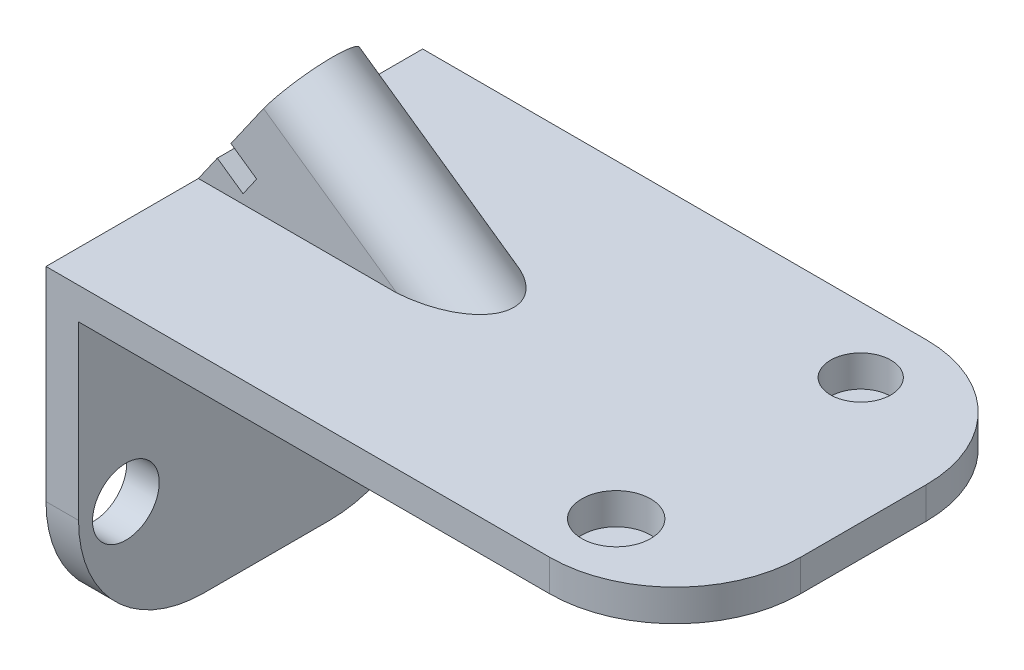
from build123d import *

# Parameters (mm, degrees)
BOSS_EXTRUDE1_DEPTH      = 50
CUT_EXTRUDE1_DEPTH       = 100
BOSS_EXTRUDE2_DEPTH      = 40
BOSS_EXTRUDE2_DEPTH_BACK = 80
SKETCH5_R                = 6.133635391
SKETCH5_W                = 29.300165504
SKETCH5_H                = 7.581524949
CUT_EXTRUDE2_DEPTH       = 10
FILLET1_R                = 40
FILLET2_R                = 40
SKETCH6_R                = 9.612627596
SKETCH6_R_2              = 10.978592339
CUT_EXTRUDE3_DEPTH       = 10
SKETCH7_R                = 10.62877533
CUT_EXTRUDE4_DEPTH       = 20


with BuildPart() as part:
    # Sketch1 → Boss-Extrude1 (new body)
    with BuildSketch(Plane.XY):
        Polygon((34.876820554, 10.095921739), (-11.47263834, 66.541302373), (-50.93851423, 10.095921739), align=None)
    extrude(amount=-BOSS_EXTRUDE1_DEPTH)

    # Sketch2 → Cut-Extrude1 (cut)
    with BuildSketch(Plane(origin=(-38.95420386, 27.236272618, 0), x_dir=(0, 0, 1), z_dir=(-0.819544824, 0.57301508, 0))):
        Polygon((-37.846995644, 47.959585147), (-37.846995644, 28.259004522), (-23.196912892, 28.259004522), (-8.54683014, 28.259004522), (0, 28.259004522), (0, 47.959585147), align=None)
        Polygon((-8.54683014, 15.307343506), (-8.54683014, -20.914476405), (0, -20.914476405), (0, 28.259004522), (-8.54683014, 28.259004522), align=None)
        with BuildLine():
            ThreePointArc((-23.196912892, 28.259004522), (-13.419765459, 24.556838072), (-8.54683014, 15.307343506))
            Line((-8.54683014, 15.307343506), (-8.54683014, 28.259004522))
            Line((-8.54683014, 28.259004522), (-23.196912892, 28.259004522))
        make_face()
        with BuildLine():
            Line((-37.846995644, 28.259004522), (-37.846995644, 15.307343506))
            ThreePointArc((-37.846995644, 15.307343506), (-32.974060325, 24.556838072), (-23.196912892, 28.259004522))
            Line((-23.196912892, 28.259004522), (-37.846995644, 28.259004522))
        make_face()
        Polygon((-50, -20.914476405), (-37.846995644, -20.914476405), (-37.846995644, 15.307343506), (-37.846995644, 28.259004522), (-37.846995644, 47.959585147), (-50, 47.959585147), align=None)
    extrude(amount=-CUT_EXTRUDE1_DEPTH, mode=Mode.SUBTRACT)

    # Sketch3 → Boss-Extrude2 (add, two sides)
    with BuildSketch(Plane.XY) as boss_extrude2_sk:
        Polygon((149.486050835, 10.095921739), (-50.93851423, 10.095921739), (-50.93851423, -94.77972655), (-40.577313053, -94.77972655), (-40.577313053, 0), (149.486050835, 0), align=None)
    extrude(amount=BOSS_EXTRUDE2_DEPTH)
    extrude(boss_extrude2_sk.sketch, amount=-BOSS_EXTRUDE2_DEPTH_BACK)

    # Sketch5 → Cut-Extrude2 (cut)
    with BuildSketch(Plane(origin=(-38.95420386, 27.236272618, 0), x_dir=(0, 0, 1), z_dir=(-0.819544824, 0.57301508, 0))):
        with Locations((-23.196912892, 13.497560131)):
            Circle(SKETCH5_R)
        with Locations((-23.196912892, -6.594328923)):
            Rectangle(SKETCH5_W, SKETCH5_H)
    extrude(amount=-CUT_EXTRUDE2_DEPTH, mode=Mode.SUBTRACT)

    # Fillet1
    fillet1_edges = [part.edges().sort_by_distance(p)[0] for p in [
        (-45.757913642, -94.77972655, -80),
        (-45.757913642, -94.77972655, 40),
    ]]
    fillet(fillet1_edges, radius=FILLET1_R)

    # Fillet2
    fillet2_edges = [part.edges().sort_by_distance(p)[0] for p in [
        (149.486050835, 5.04796087, -80),
        (149.486050835, 5.04796087, 40),
    ]]
    fillet(fillet2_edges, radius=FILLET2_R)

    # Sketch6 → Cut-Extrude3 (cut)
    with BuildSketch(Plane(origin=(0, 10.095921739, 0), x_dir=(1, 0, 0), z_dir=(0, 1, 0))):
        with Locations((109.486050835, 59.137142256)):
            Circle(SKETCH6_R)
        with Locations((109.486050835, -18.771374572)):
            Circle(SKETCH6_R_2)
    extrude(amount=-CUT_EXTRUDE3_DEPTH, mode=Mode.SUBTRACT)

    # Sketch7 → Cut-Extrude4 (cut)
    with BuildSketch(Plane.ZY.offset(50.93851423)):
        with Locations((-63.54369248, -57.164065998)):
            Circle(SKETCH7_R)
        with Locations((24.915147361, -57.164065998)):
            Circle(SKETCH7_R)
    extrude(amount=-CUT_EXTRUDE4_DEPTH, mode=Mode.SUBTRACT)


solid = part.part
